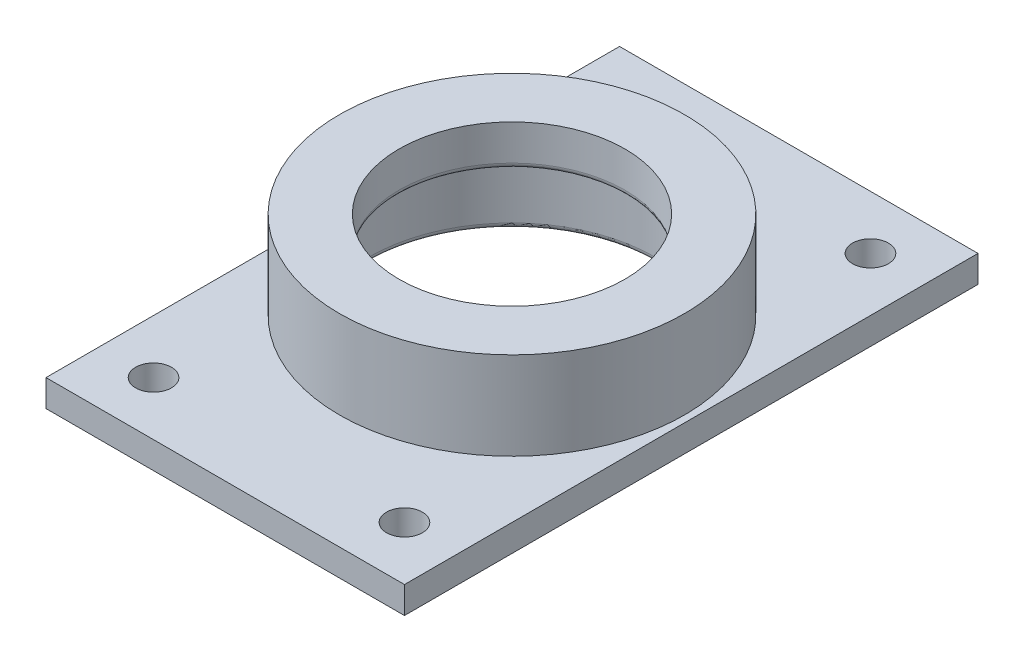
from build123d import *

# Parameters (mm, degrees)
SKETCH1_R           = 30.55
BOSS_EXTRUDE1_DEPTH = 20.32
SKETCH2_R           = 25.404
CUT_EXTRUDE1_DEPTH  = 13
SKETCH3_R           = 20
CUT_EXTRUDE2_DEPTH  = 21.32
FILLET1_R           = 1
FILLET2_R           = 1
SKETCH4_W           = 63.5
SKETCH4_H           = 101.6
SKETCH4_R           = 3.175
SKETCH4_R_2         = 26.404
BOSS_EXTRUDE2_DEPTH = 4.7625


with BuildPart() as part:
    # Sketch1 → Boss-Extrude1 (new body)
    with BuildSketch(Plane(origin=(0, 0, 0), x_dir=(1, 0, 0), z_dir=(0, 1, 0))):
        Circle(SKETCH1_R)
    extrude(amount=BOSS_EXTRUDE1_DEPTH)

    # Sketch2 → Cut-Extrude1 (cut)
    with BuildSketch(Plane.XZ):
        Circle(SKETCH2_R)
    extrude(amount=-CUT_EXTRUDE1_DEPTH, mode=Mode.SUBTRACT)

    # Sketch3 → Cut-Extrude2 (cut, through all)
    with BuildSketch(Plane(origin=(0, 20.32, 0), x_dir=(1, 0, 0), z_dir=(0, 1, 0))):
        Circle(SKETCH3_R)
    extrude(amount=-CUT_EXTRUDE2_DEPTH, mode=Mode.SUBTRACT)

    # Fillet1
    fillet1_edges = [part.edges().sort_by_distance(p)[0] for p in [
        (-25.404, 0, 0),
    ]]
    fillet(fillet1_edges, radius=FILLET1_R)

    # Fillet2
    fillet2_edges = [part.edges().sort_by_distance(p)[0] for p in [
        (-20, 13, 0),
    ]]
    fillet(fillet2_edges, radius=FILLET2_R)

    # Sketch4 → Boss-Extrude2 (add)
    with BuildSketch(Plane.XZ):
        Rectangle(SKETCH4_W, SKETCH4_H)
        with Locations((-22.225, 41.275)):
            Circle(SKETCH4_R, mode=Mode.SUBTRACT)
        with Locations((22.225, 41.275)):
            Circle(SKETCH4_R, mode=Mode.SUBTRACT)
        with Locations((22.225, -41.275)):
            Circle(SKETCH4_R, mode=Mode.SUBTRACT)
        with Locations((-22.225, -41.275)):
            Circle(SKETCH4_R, mode=Mode.SUBTRACT)
        Circle(SKETCH4_R_2, mode=Mode.SUBTRACT)
    extrude(amount=-BOSS_EXTRUDE2_DEPTH)


solid = part.part
